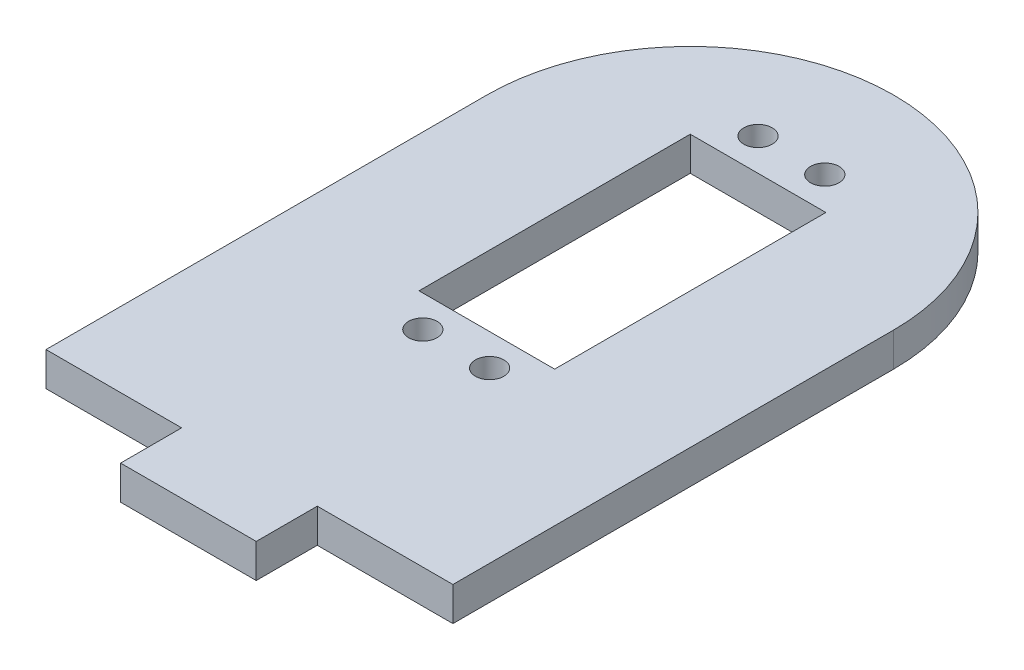
from build123d import *

# Parameters (mm, degrees)
SKETCH1_W               = 60
SKETCH1_H               = 65
SKETCH1_W_2             = 20
SKETCH1_H_2             = 9
BOSS_EXTRUDE1_DEPTH     = 5
SKETCH2_W               = 20
SKETCH2_H               = 40
CUT_EXTRUDE1_DEPTH      = 6
SKETCH3_R               = 2.1
CUT_EXTRUDE2_DEPTH      = 1
CUT_EXTRUDE2_DEPTH_BACK = 6


with BuildPart() as part:
    # Sketch1 → Boss-Extrude1 (new body)
    with BuildSketch(Plane(origin=(0, 0, 0), x_dir=(1, 0, 0), z_dir=(0, 1, 0))):
        Rectangle(SKETCH1_W, SKETCH1_H)
        with Locations((0, -37)):
            Rectangle(SKETCH1_W_2, SKETCH1_H_2)
        with BuildLine():
            Line((-30, 32.5), (30, 32.5))
            ThreePointArc((30, 32.5), (0, 62.5), (-30, 32.5))
        make_face()
    extrude(amount=BOSS_EXTRUDE1_DEPTH)

    # Sketch2 → Cut-Extrude1 (cut, through all)
    with BuildSketch(Plane(origin=(0, 5, 0), x_dir=(1, 0, 0), z_dir=(0, 1, 0))):
        with Locations((0, 22.5)):
            Rectangle(SKETCH2_W, SKETCH2_H)
    extrude(amount=-CUT_EXTRUDE1_DEPTH, mode=Mode.SUBTRACT)

    # Sketch3 → Cut-Extrude2 (cut, two sides)
    with BuildSketch(Plane.XZ) as cut_extrude2_sk:
        with Locations((-4.775, 2.161145618)):
            Circle(SKETCH3_R)
        with Locations((5.075, 2.161145618)):
            Circle(SKETCH3_R)
        with Locations((5.075, -47.261145618)):
            Circle(SKETCH3_R)
        with Locations((-4.775, -47.261145618)):
            Circle(SKETCH3_R)
    extrude(amount=CUT_EXTRUDE2_DEPTH, mode=Mode.SUBTRACT)
    extrude(cut_extrude2_sk.sketch, amount=-CUT_EXTRUDE2_DEPTH_BACK, mode=Mode.SUBTRACT)


solid = part.part
